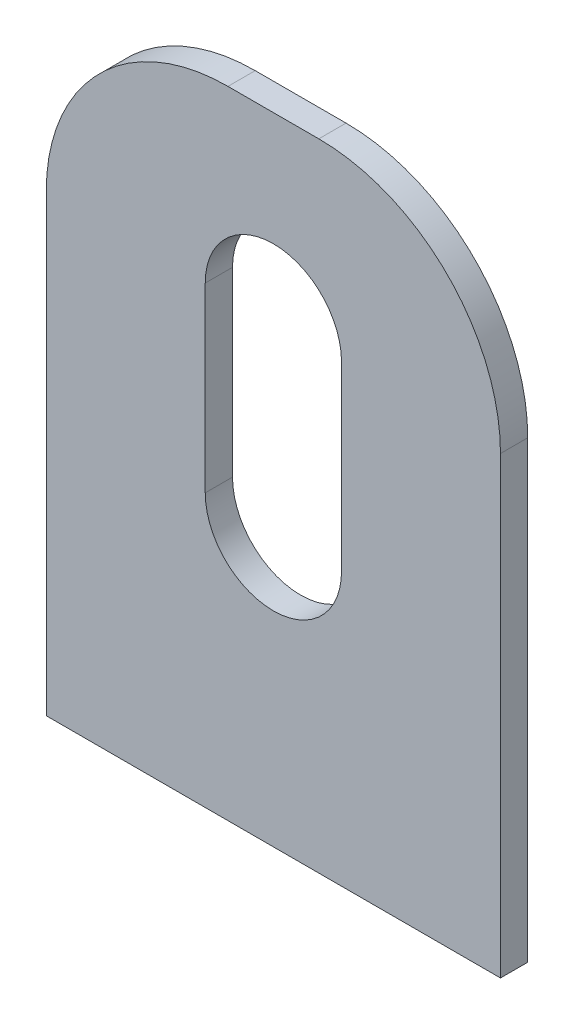
from build123d import *

# Parameters (mm, degrees)
SKETCH1_W               = 50
SKETCH1_H               = 70
BOSS_EXTRUDE1_DEPTH     = 3
CUT_EXTRUDE1_DEPTH      = 1
CUT_EXTRUDE1_DEPTH_BACK = 4
FILLET1_R               = 20


with BuildPart() as part:
    # Sketch1 → Boss-Extrude1 (new body)
    with BuildSketch(Plane.XY):
        with Locations((0, 5)):
            Rectangle(SKETCH1_W, SKETCH1_H)
    extrude(amount=BOSS_EXTRUDE1_DEPTH)

    # Sketch2 → Cut-Extrude1 (cut, two sides)
    with BuildSketch(Plane.XY.offset(3)) as cut_extrude1_sk:
        with BuildLine():
            Line((-7.5, 0), (-7.5, 20))
            ThreePointArc((-7.5, 20), (0, 27.5), (7.5, 20))
            Line((7.5, 20), (7.5, 0))
            ThreePointArc((7.5, 0), (0, -7.5), (-7.5, 0))
        make_face()
    extrude(amount=CUT_EXTRUDE1_DEPTH, mode=Mode.SUBTRACT)
    extrude(cut_extrude1_sk.sketch, amount=-CUT_EXTRUDE1_DEPTH_BACK, mode=Mode.SUBTRACT)

    # Fillet1
    fillet1_edges = [part.edges().sort_by_distance(p)[0] for p in [
        (-25, 40, 1.5),
        (25, 40, 1.5),
    ]]
    fillet(fillet1_edges, radius=FILLET1_R)


solid = part.part
